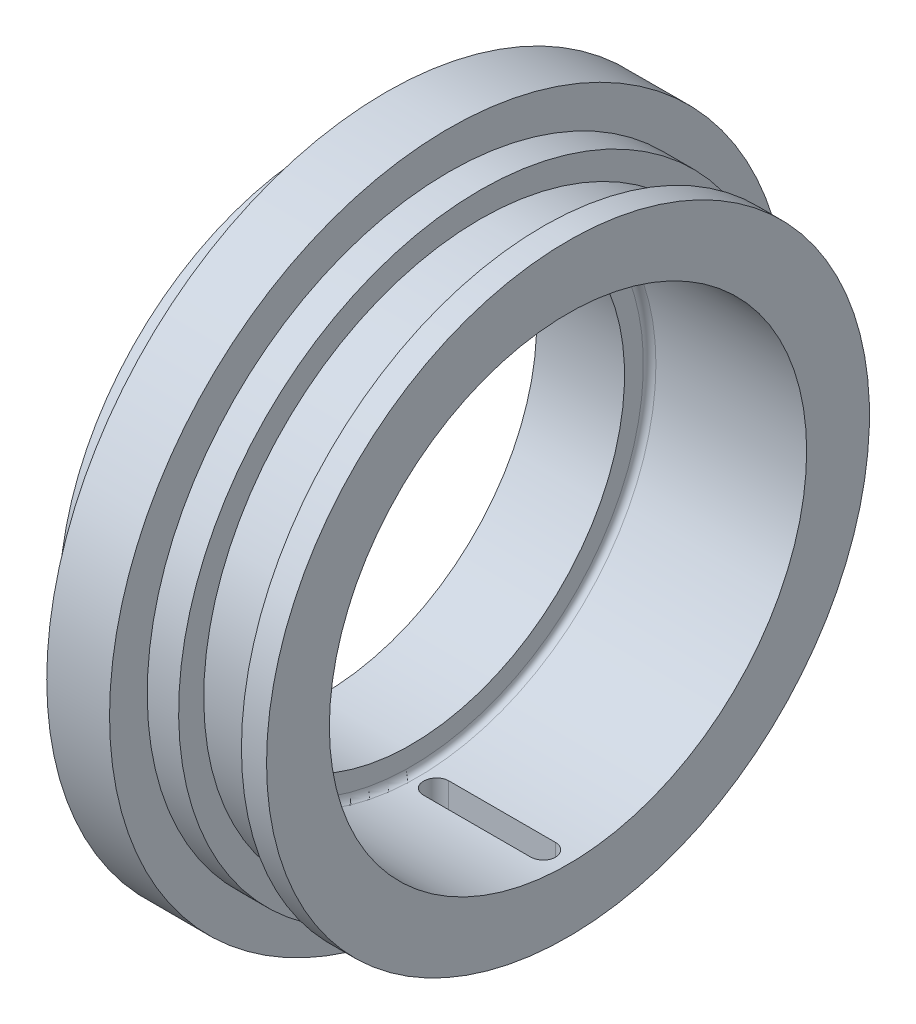
from build123d import *

# Parameters (mm, degrees)
ZAOBLIT1_R               = 0.5
ODEBRAT_START            = -8
ODEBRAT_VYSUNUT_M2_DEPTH = 8.026334


with BuildPart() as part:
    # Skica1 → Rotovat1 (revolve)
    with BuildSketch(Plane.XY):
        Polygon((-351.05, 24), (-353.05, 24), (-353.05, 22), (-358.05, 22), (-358.05, 24), (-360.55, 24), (-360.55, 27), (-365.55, 27), (-365.55, 20), (-367.05, 20), (-367.55, 21), (-370.55, 21), (-370.55, 19), (-370.55, 17), (-363.55, 17), (-363.55, 19), (-351.05, 19), align=None)
    revolve(axis=Axis((-379.936676629, 0, 0), (1, 0, 0)))

    # Zaoblit1
    zaoblit1_edges = [part.edges().sort_by_distance(p)[0] for p in [
        (-363.55, -19, 0),
    ]]
    fillet(zaoblit1_edges, radius=ZAOBLIT1_R)

    # Skica3 → Odebrat vysunutím2 (cut)
    with BuildSketch(Plane(origin=(0, -19, 0), x_dir=(1, 0, 0), z_dir=(0, 1, 0)).offset(ODEBRAT_START)):
        with BuildLine():
            Line((-353.05, -1), (-361.55, -1))
            ThreePointArc((-361.55, -1), (-362.55, 0), (-361.55, 1))
            Line((-361.55, 1), (-353.05, 1))
            ThreePointArc((-353.05, 1), (-352.05, 0), (-353.05, -1))
        make_face()
    extrude(amount=ODEBRAT_VYSUNUT_M2_DEPTH, mode=Mode.SUBTRACT)


solid = part.part
